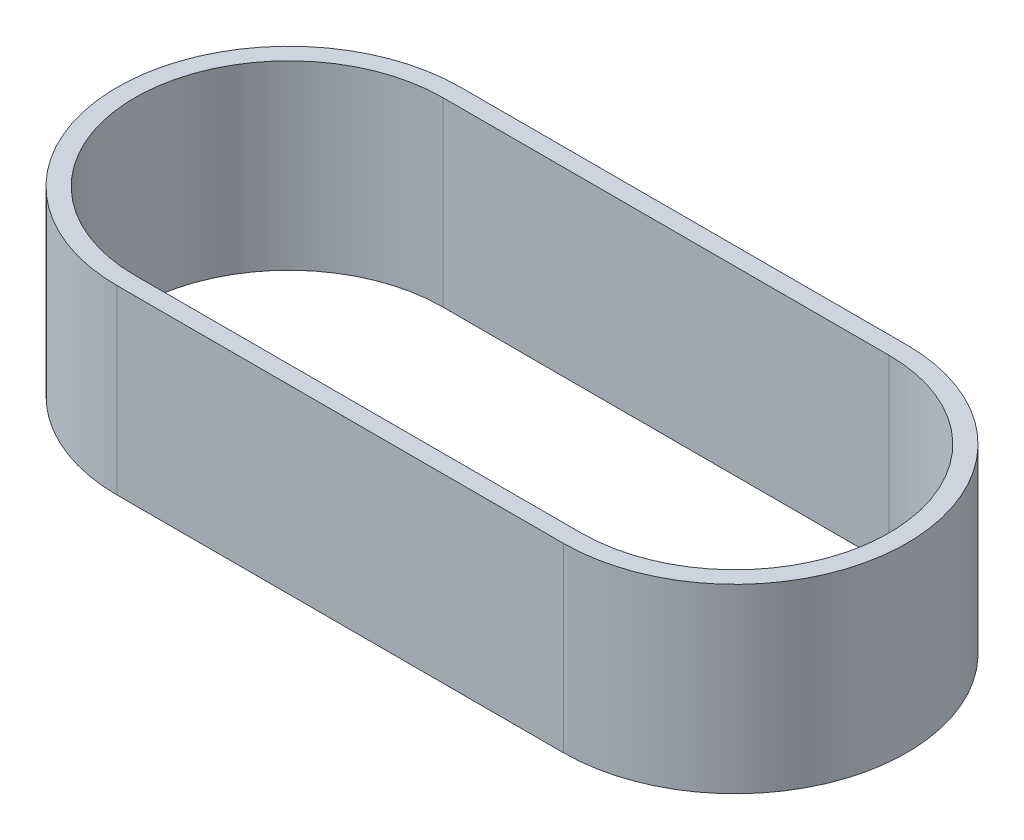
from build123d import *

# Parameters (mm, degrees)
BOSS_EXTRUDE1_DEPTH = 20.32


with BuildPart() as part:
    # Sketch1 → Boss-Extrude1 (new body)
    with BuildSketch(Plane(origin=(0, 0, 0), x_dir=(1, 0, 0), z_dir=(0, 1, 0))):
        with BuildLine():
            Line((-85.13381171, 52.417862554), (-35.13381171, 52.417862554))
            ThreePointArc((-35.13381171, 52.417862554), (-15.889562986, 33.17361383), (-35.13381171, 13.929365106))
            Line((-35.13381171, 13.929365106), (-85.13381171, 13.929365106))
            ThreePointArc((-85.13381171, 13.929365106), (-104.378060434, 33.17361383), (-85.13381171, 52.417862554))
        make_face()
        with BuildLine():
            Line((-85.13381171, 50.417862554), (-35.13381171, 50.417862554))
            ThreePointArc((-35.13381171, 50.417862554), (-17.889562986, 33.17361383), (-35.13381171, 15.929365106))
            Line((-35.13381171, 15.929365106), (-85.13381171, 15.929365106))
            ThreePointArc((-85.13381171, 15.929365106), (-102.378060434, 33.17361383), (-85.13381171, 50.417862554))
        make_face(mode=Mode.SUBTRACT)
    extrude(amount=BOSS_EXTRUDE1_DEPTH)


solid = part.part
